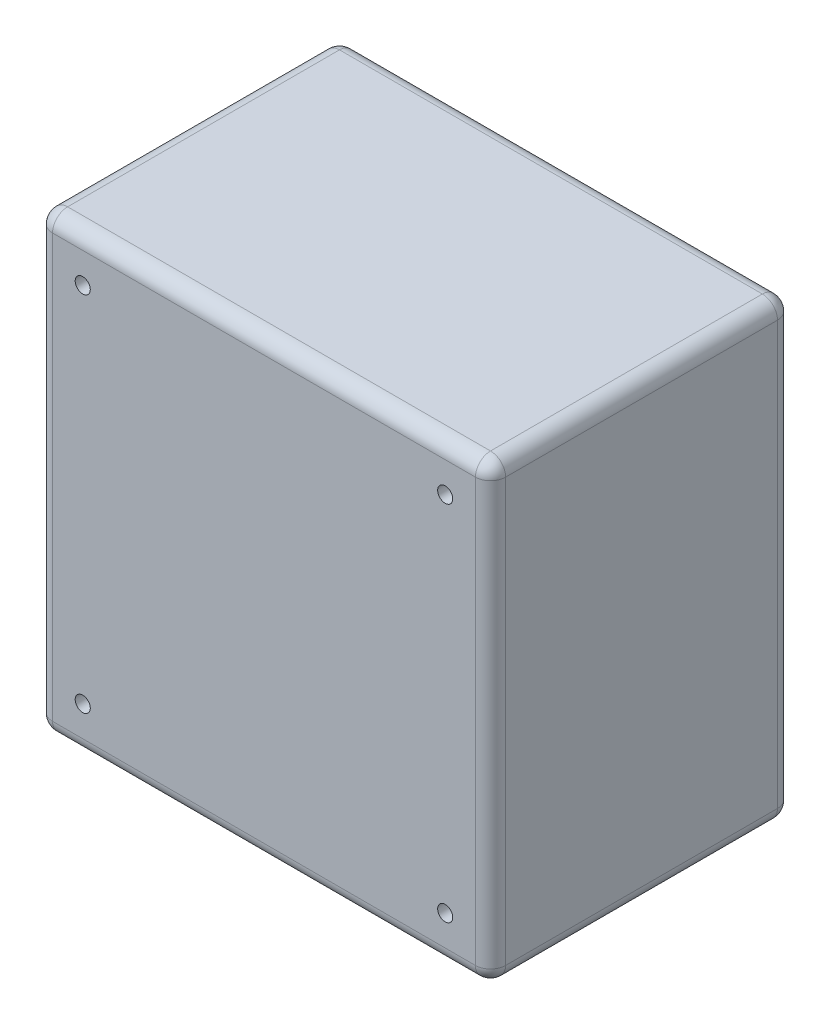
from build123d import *

# Parameters (mm, degrees)
SKETCH_1_W        = 150
SKETCH_1_H        = 150
SKETCH_1_R        = 2.5
EXTRUDE_1_DEPTH   = 100
FILLET_1_R        = 5
SKETCH_1_2_R      = 2.5
EXTRUDE_2_DEPTH   = 8
EXTRUDE_2_2_DEPTH = 8
EXTRUDE_2_3_DEPTH = 8
EXTRUDE_2_4_DEPTH = 8


with BuildPart() as part:
    # 스케치1 → 보스-돌출1 (new body)
    with BuildSketch(Plane.XY):
        with Locations((75, -75)):
            Rectangle(SKETCH_1_W, SKETCH_1_H)
        with Locations((15, -15)):
            Circle(SKETCH_1_R, mode=Mode.SUBTRACT)
        with Locations((15, -135)):
            Circle(SKETCH_1_R, mode=Mode.SUBTRACT)
        with Locations((135, -15)):
            Circle(SKETCH_1_R, mode=Mode.SUBTRACT)
        with Locations((135, -135)):
            Circle(SKETCH_1_R, mode=Mode.SUBTRACT)
    extrude(amount=EXTRUDE_1_DEPTH)

    # 필렛1
    fillet_1_edges = [part.edges().sort_by_distance(p)[0] for p in [
        (75, -150, 100),
        (75, -150, 0),
        (0, -75, 100),
        (0, -150, 50),
        (0, -75, 0),
        (75, 0, 100),
        (0, 0, 50),
        (75, 0, 0),
        (150, -150, 50),
        (150, -75, 100),
        (150, 0, 50),
        (150, -75, 0),
    ]]
    fillet(fillet_1_edges, radius=FILLET_1_R)


with BuildPart() as body_2:
    # 스케치1<2> → 보스-돌출2 (new body)
    with BuildSketch(Plane.XY):
        with Locations((15, -15)):
            Circle(SKETCH_1_2_R)
    extrude(amount=-EXTRUDE_2_DEPTH)


with BuildPart() as body_3:
    # 스케치1<2> → Extrude 2 2 (new body)
    with BuildSketch(Plane.XY):
        with Locations((15, -135)):
            Circle(SKETCH_1_2_R)
    extrude(amount=-EXTRUDE_2_2_DEPTH)


with BuildPart() as body_4:
    # 스케치1<2> → Extrude 2 3 (new body)
    with BuildSketch(Plane.XY):
        with Locations((135, -15)):
            Circle(SKETCH_1_2_R)
    extrude(amount=-EXTRUDE_2_3_DEPTH)


with BuildPart() as body_5:
    # 스케치1<2> → Extrude 2 4 (new body)
    with BuildSketch(Plane.XY):
        with Locations((135, -135)):
            Circle(SKETCH_1_2_R)
    extrude(amount=-EXTRUDE_2_4_DEPTH)


solid = Compound([part.part, body_2.part, body_3.part, body_4.part, body_5.part])
